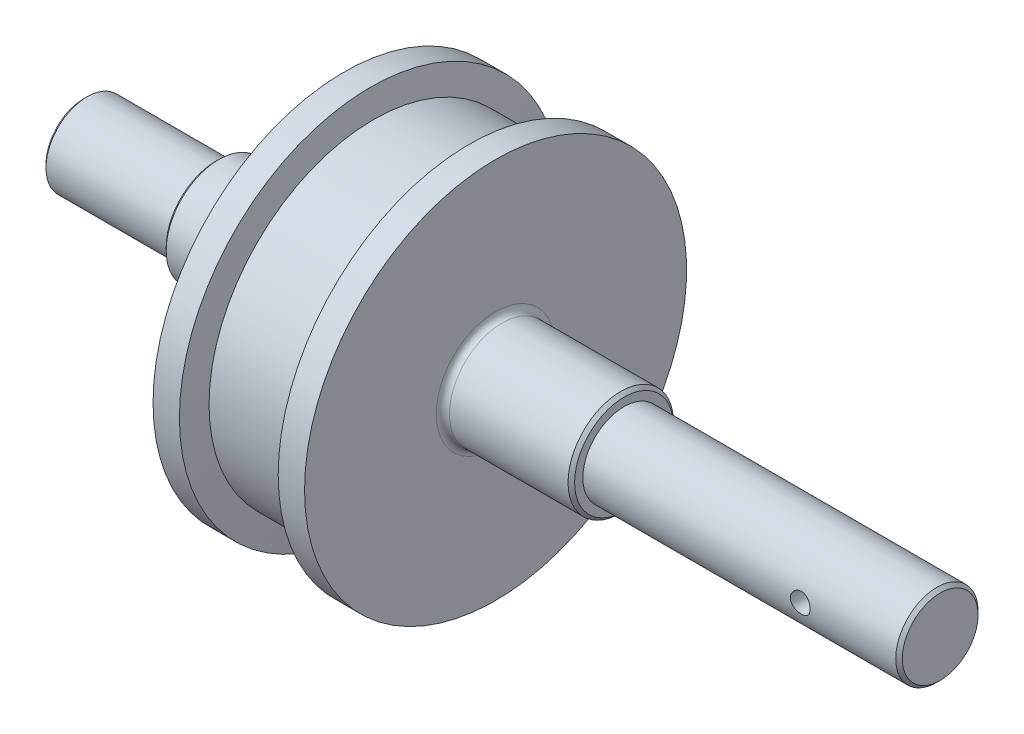
from build123d import *

# Parameters (mm, degrees)
SKETCH_2_R          = 3
CUT_EXTRUDE_1_DEPTH = 15


with BuildPart() as part:
    # 草图1 → 旋转1 (revolve)
    with BuildSketch(Plane.XY):
        with BuildLine():
            Line((41, 16), (77, 16))
            ThreePointArc((77, 16), (78.414213562, 16.585786438), (79, 18))
            Line((79, 18), (79, 58))
            Line((79, 58), (87, 58))
            Line((87, 58), (88, 50))
            Line((88, 50), (116, 50))
            Line((116, 50), (117, 58))
            Line((117, 58), (125, 58))
            Line((125, 58), (125, 18))
            ThreePointArc((125, 18), (125.585786438, 16.585786438), (127, 16))
            Line((127, 16), (163, 16))
            Line((163, 16), (164, 15))
            Line((164, 15), (164, 12.5))
            Line((164, 12.5), (259, 12.5))
            Line((259, 12.5), (260, 11.5))
            Line((260, 11.5), (260, 0))
            Line((260, 0), (0, 0))
            Line((0, 0), (0, 11.5))
            Line((0, 11.5), (1, 12.5))
            Line((1, 12.5), (40, 12.5))
            Line((40, 12.5), (40, 15))
            Line((40, 15), (41, 16))
        make_face()
    revolve(axis=Axis((0, 0, 0), (1, 0, 0)))

    # 草图2 → 切除-拉伸1 (cut, symmetric)
    with BuildSketch(Plane.XY):
        with Locations((230, 0)):
            Circle(SKETCH_2_R)
    extrude(amount=CUT_EXTRUDE_1_DEPTH, both=True, mode=Mode.SUBTRACT)


solid = part.part
